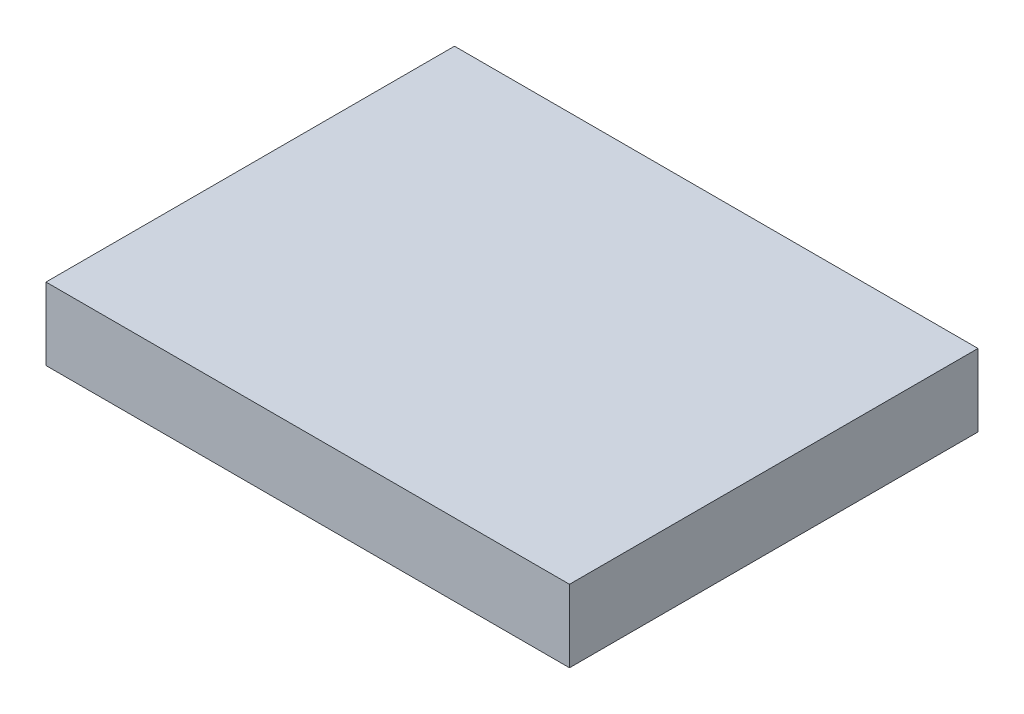
from build123d import *

# Parameters (mm, degrees)
SKETCH1_W           = 31.212281817
SKETCH1_H           = 5.527914637
BOSS_EXTRUDE1_DEPTH = 40


with BuildPart() as part:
    # Sketch1 → Boss-Extrude1 (new body)
    with BuildSketch(Plane.ZY.offset(251.645231304)):
        with Locations((-433.173622158, -102.884851267)):
            Rectangle(SKETCH1_W, SKETCH1_H)
    extrude(amount=BOSS_EXTRUDE1_DEPTH)


solid = part.part
